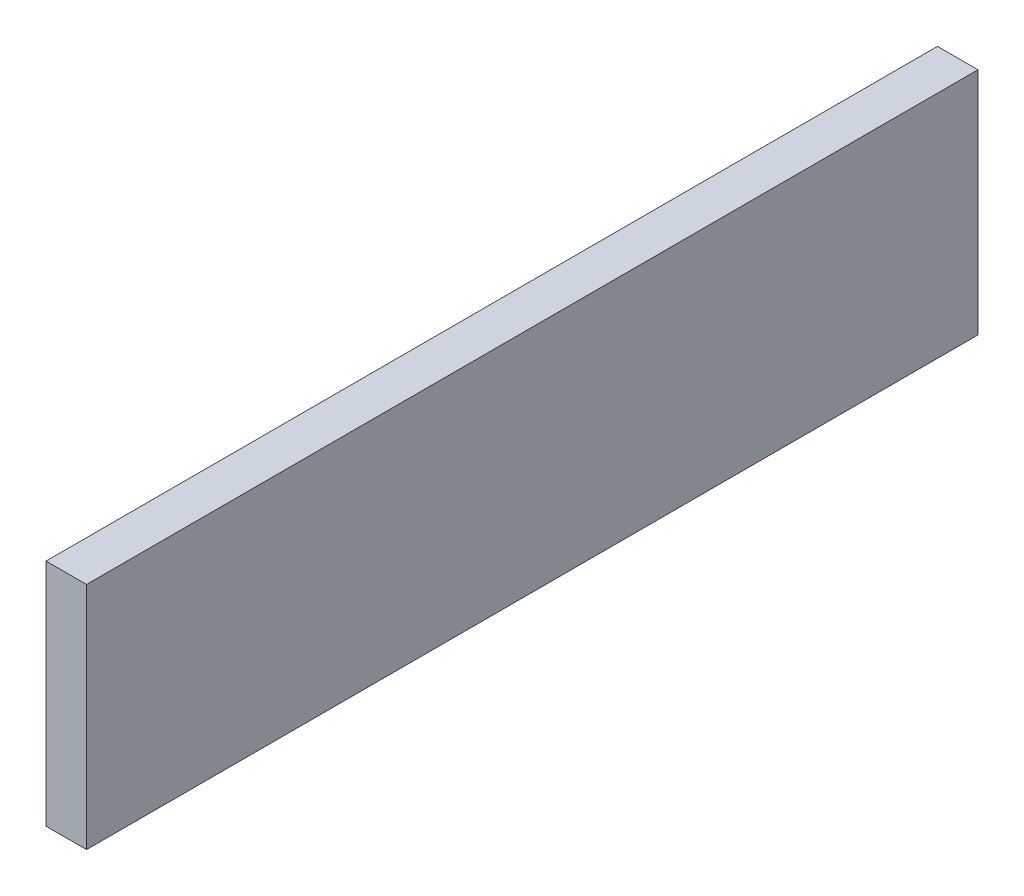
from build123d import *

# Parameters (mm, degrees)
SKETCH1_W           = 419.1
SKETCH1_H           = 107.95
BOSS_EXTRUDE1_DEPTH = 19.05


with BuildPart() as part:
    # Sketch1 → Boss-Extrude1 (new body)
    with BuildSketch(Plane(origin=(0, 0, 0), x_dir=(0, 0, -1), z_dir=(1, 0, 0))):
        with Locations((209.55, 53.975)):
            Rectangle(SKETCH1_W, SKETCH1_H)
    extrude(amount=BOSS_EXTRUDE1_DEPTH)


solid = part.part
